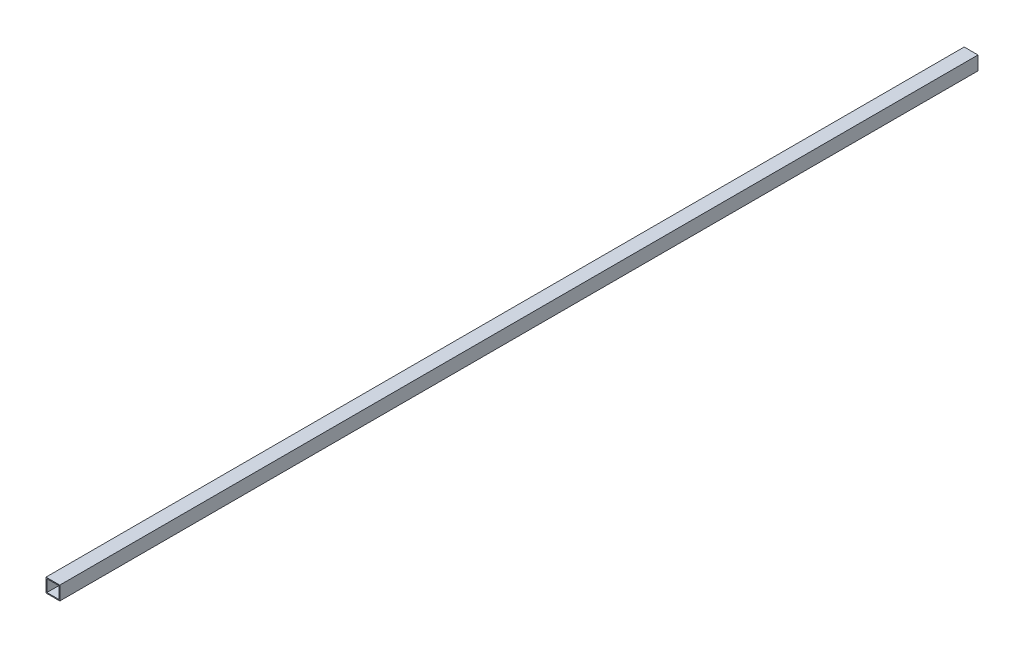
from build123d import *

# Parameters (mm, degrees)
SKETCH1_W           = 30
SKETCH1_H           = 30
SKETCH1_W_2         = 26
SKETCH1_H_2         = 26
BOSS_EXTRUDE1_DEPTH = 1995.5


with BuildPart() as part:
    # Sketch1 → Boss-Extrude1 (new body)
    with BuildSketch(Plane.XY):
        Rectangle(SKETCH1_W, SKETCH1_H)
        Rectangle(SKETCH1_W_2, SKETCH1_H_2, mode=Mode.SUBTRACT)
    extrude(amount=BOSS_EXTRUDE1_DEPTH)


solid = part.part
